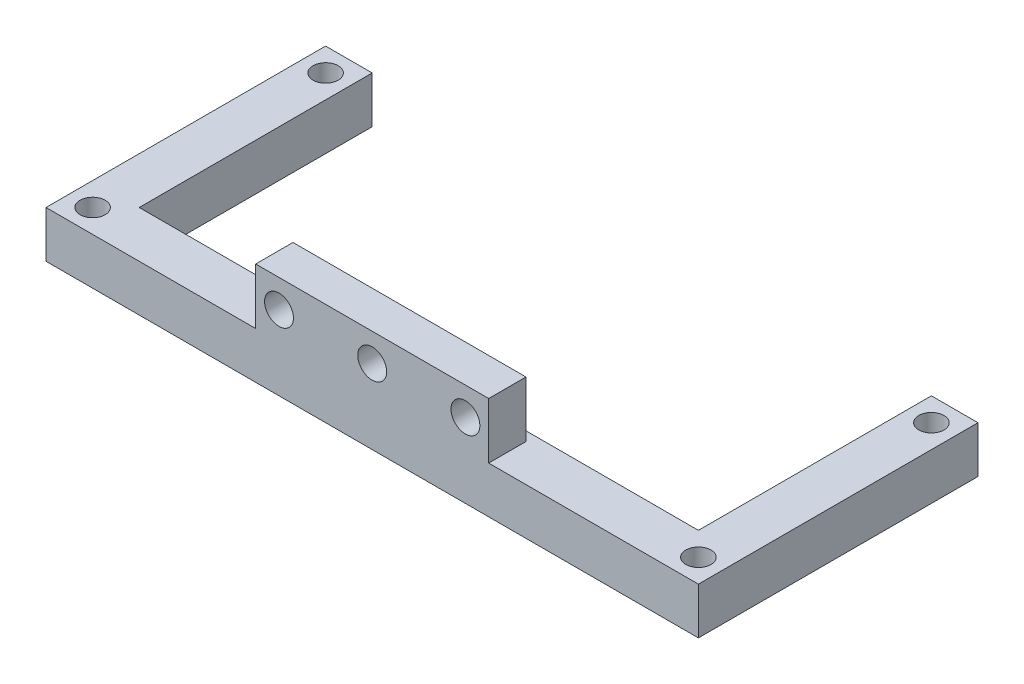
from build123d import *

# Parameters (mm, degrees)
SKETCH1_W           = 70
SKETCH1_H           = 30
BOSS_EXTRUDE1_DEPTH = 5
SKETCH2_R           = 1.35
CUT_EXTRUDE1_DEPTH  = 6
SKETCH3_W           = 25
SKETCH3_H           = 4
BOSS_EXTRUDE2_DEPTH = 6
SKETCH4_R           = 1.55
CUT_EXTRUDE2_DEPTH  = 5
SKETCH5_W           = 60
SKETCH5_H           = 25
CUT_EXTRUDE3_DEPTH  = 6


with BuildPart() as part:
    # Sketch1 → Boss-Extrude1 (new body)
    with BuildSketch(Plane(origin=(0, 0, 0), x_dir=(1, 0, 0), z_dir=(0, 1, 0))):
        Rectangle(SKETCH1_W, SKETCH1_H)
    extrude(amount=BOSS_EXTRUDE1_DEPTH)

    # Sketch2 → Cut-Extrude1 (cut, through all)
    with BuildSketch(Plane(origin=(0, 5, 0), x_dir=(1, 0, 0), z_dir=(0, 1, 0))):
        with Locations((-32.5, 12.5)):
            Circle(SKETCH2_R)
        with Locations((32.5, 12.5)):
            Circle(SKETCH2_R)
        with Locations((-32.5, -12.5)):
            Circle(SKETCH2_R)
        with Locations((32.5, -12.5)):
            Circle(SKETCH2_R)
    extrude(amount=-CUT_EXTRUDE1_DEPTH, mode=Mode.SUBTRACT)

    # Sketch3 → Boss-Extrude2 (add)
    with BuildSketch(Plane(origin=(0, 5, 0), x_dir=(1, 0, 0), z_dir=(0, 1, 0))):
        with Locations((0, -13)):
            Rectangle(SKETCH3_W, SKETCH3_H)
    extrude(amount=BOSS_EXTRUDE2_DEPTH)

    # Sketch4 → Cut-Extrude2 (cut, through all)
    with BuildSketch(Plane(origin=(0, 0, 11), x_dir=(-1, 0, 0), z_dir=(0, 0, -1))):
        with Locations((-10, 8)):
            Circle(SKETCH4_R)
        with Locations((0, 8)):
            Circle(SKETCH4_R)
        with Locations((10, 8)):
            Circle(SKETCH4_R)
    extrude(amount=-CUT_EXTRUDE2_DEPTH, mode=Mode.SUBTRACT)

    # Sketch5 → Cut-Extrude3 (cut, through all)
    with BuildSketch(Plane(origin=(0, 5, 0), x_dir=(1, 0, 0), z_dir=(0, 1, 0))):
        with Locations((0, 2.5)):
            Rectangle(SKETCH5_W, SKETCH5_H)
    extrude(amount=-CUT_EXTRUDE3_DEPTH, mode=Mode.SUBTRACT)


solid = part.part
